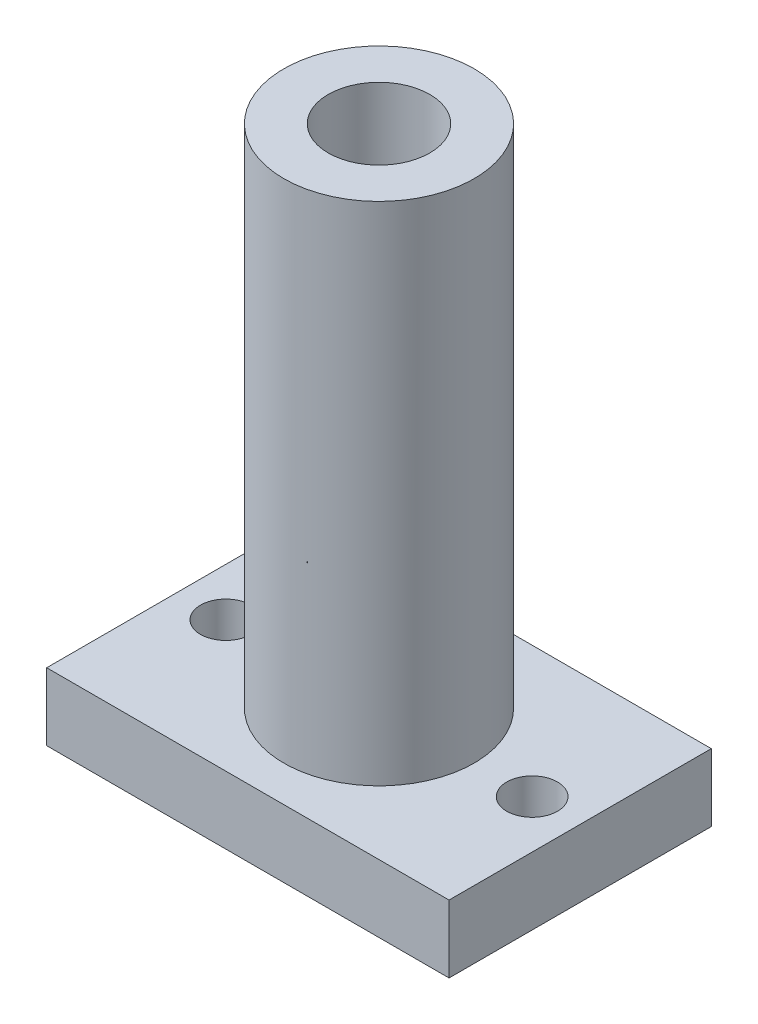
from build123d import *

# Parameters (mm, degrees)
SKETCH1_W           = 31.7
SKETCH1_H           = 20.66
BOSS_EXTRUDE1_DEPTH = 5.32
SKETCH2_R           = 2
CUT_EXTRUDE1_DEPTH  = 5.32
SKETCH3_R           = 7.5
SKETCH3_R_2         = 4
BOSS_EXTRUDE2_DEPTH = 39.88
SKETCH4_R           = 4
CUT_EXTRUDE2_DEPTH  = 39.88


with BuildPart() as part:
    # Sketch1 → Boss-Extrude1 (new body)
    with BuildSketch(Plane(origin=(0, 0, 0), x_dir=(1, 0, 0), z_dir=(0, 1, 0))):
        with Locations((15.85, 10.33)):
            Rectangle(SKETCH1_W, SKETCH1_H)
    extrude(amount=BOSS_EXTRUDE1_DEPTH)

    # Sketch2 → Cut-Extrude1 (cut)
    with BuildSketch(Plane(origin=(0, 5.32, 0), x_dir=(1, 0, 0), z_dir=(0, 1, 0))):
        with Locations((3.785, 10.33)):
            Circle(SKETCH2_R)
        with Locations((27.915, 10.33)):
            Circle(SKETCH2_R)
    extrude(amount=-CUT_EXTRUDE1_DEPTH, mode=Mode.SUBTRACT)

    # Sketch3 → Boss-Extrude2 (add)
    with BuildSketch(Plane(origin=(0, 5.32, 0), x_dir=(1, 0, 0), z_dir=(0, 1, 0))):
        with Locations((15.85, 10.33)):
            Circle(SKETCH3_R)
        with Locations((15.85, 10.33)):
            Circle(SKETCH3_R_2, mode=Mode.SUBTRACT)
    extrude(amount=BOSS_EXTRUDE2_DEPTH)

    # Sketch4 → Cut-Extrude2 (cut)
    with BuildSketch(Plane(origin=(0, 5.32, 0), x_dir=(1, 0, 0), z_dir=(0, 1, 0))):
        with Locations((15.85, 10.33)):
            Circle(SKETCH4_R)
    extrude(amount=-CUT_EXTRUDE2_DEPTH, mode=Mode.SUBTRACT)


solid = part.part
